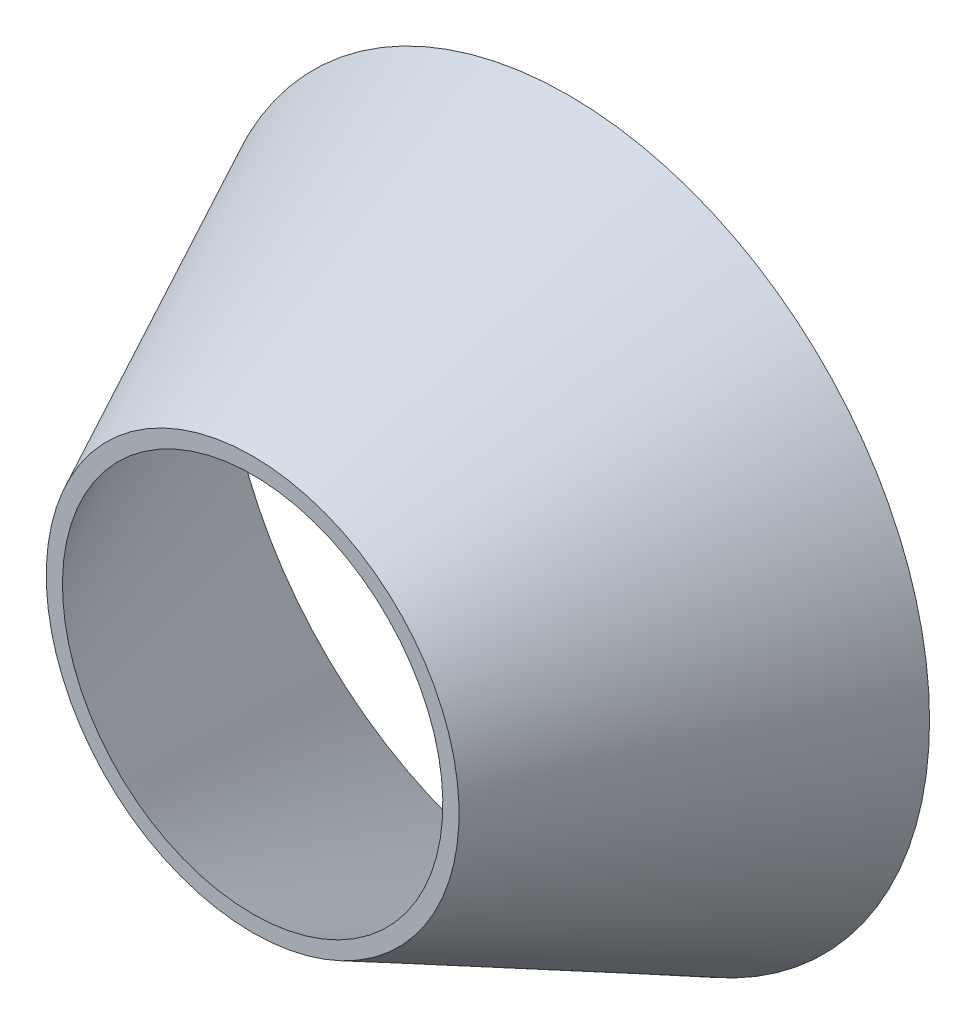
from build123d import *


with BuildPart() as part:
    # Sketch1 → Revolve1 (revolve)
    with BuildSketch(Plane(origin=(0, 0, 0), x_dir=(0, 0, -1), z_dir=(1, 0, 0))):
        Polygon((1892.517080646, 283.47969619), (2326.389140959, 495.795249314), (2326.389140959, 473.529005716), (1892.517080646, 261.213452592), align=None)
    revolve(axis=Axis((0, 0, -1891.07774677), (0, 0, -1)))


solid = part.part
